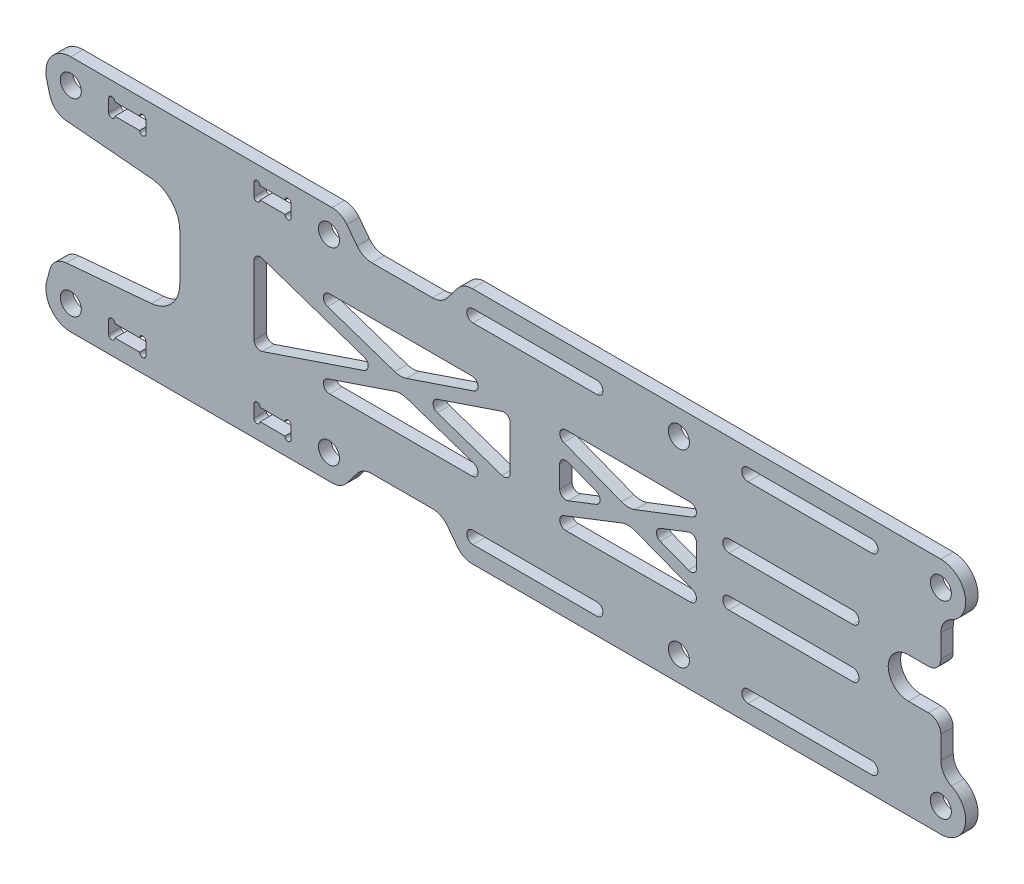
from build123d import *

# Parameters (mm, degrees)
BOSS_EXTRUDE1_DEPTH      = 2
M3_CLEARANCE_HOLE1_D     = 3.4
M3_CLEARANCE_HOLE1_DEPTH = 2


with BuildPart() as part:
    # Sketch1 → Boss-Extrude1 (new body)
    with BuildSketch(Plane.XY):
        with BuildLine():
            Line((-70.9498441, 19.25), (-28.751239803, 19.25))
            ThreePointArc((-28.751239803, 19.25), (-27.425268349, 18.941059216), (-26.372394669, 18.077866469))
            Line((-26.372394669, 18.077866469), (-24.716158925, 15.922387167))
            ThreePointArc((-24.716158925, 15.922387167), (-23.663285245, 15.05919442), (-22.337313791, 14.750253636))
            Line((-22.337313791, 14.750253636), (-12.526963734, 14.750253636))
            ThreePointArc((-12.526963734, 14.750253636), (-11.200992281, 15.05919442), (-10.1481186, 15.922387167))
            Line((-10.1481186, 15.922387167), (-8.491882857, 18.077866469))
            ThreePointArc((-8.491882857, 18.077866469), (-7.439009177, 18.941059216), (-6.113037723, 19.25))
            Line((-6.113037723, 19.25), (69.560347596, 19.25))
            ThreePointArc((69.560347596, 19.25), (73.462662706, 16.128599327), (71.27463331, 11.635968388))
            ThreePointArc((71.27463331, 11.635968388), (70.024884831, 10.529012131), (69.560347596, 8.92544468))
            Line((69.560347596, 8.92544468), (69.560347596, 5.25))
            ThreePointArc((69.560347596, 5.25), (68.974561158, 3.835786438), (67.560347596, 3.25))
            Line((67.560347596, 3.25), (64.309156116, 3.25))
            ThreePointArc((64.309156116, 3.25), (61.059156116, 0), (64.309156116, -3.25))
            Line((64.309156116, -3.25), (67.560347596, -3.25))
            ThreePointArc((67.560347596, -3.25), (68.974561158, -3.835786438), (69.560347596, -5.25))
            Line((69.560347596, -5.25), (69.560347596, -8.92544468))
            ThreePointArc((69.560347596, -8.92544468), (70.024884831, -10.529012131), (71.27463331, -11.635968388))
            ThreePointArc((71.27463331, -11.635968388), (73.462662706, -16.128599327), (69.560347596, -19.25))
            Line((69.560347596, -19.25), (-6.113037723, -19.25))
            ThreePointArc((-6.113037723, -19.25), (-7.439009177, -18.941059216), (-8.491882857, -18.077866469))
            Line((-8.491882857, -18.077866469), (-10.1481186, -15.922387167))
            ThreePointArc((-10.1481186, -15.922387167), (-11.200992281, -15.05919442), (-12.526963734, -14.750253636))
            Line((-12.526963734, -14.750253636), (-22.337313791, -14.750253636))
            ThreePointArc((-22.337313791, -14.750253636), (-23.663285245, -15.05919442), (-24.716158925, -15.922387167))
            Line((-24.716158925, -15.922387167), (-26.372394669, -18.077866469))
            ThreePointArc((-26.372394669, -18.077866469), (-27.425268349, -18.941059216), (-28.751239803, -19.25))
            Line((-28.751239803, -19.25), (-70.9498441, -19.25))
            ThreePointArc((-70.9498441, -19.25), (-73.778271225, -18.078427125), (-74.9498441, -15.25))
            Line((-74.9498441, -15.25), (-74.9498441, -14.5))
            Line((-74.9498441, -14.5), (-74.322497457, -12.158710455))
            ThreePointArc((-74.322497457, -12.158710455), (-73.353082807, -10.637034261), (-71.686187206, -9.946583496))
            Line((-71.686187206, -9.946583496), (-57.912189979, -8.741514887))
            ThreePointArc((-57.912189979, -8.741514887), (-54.661582009, -7.138492435), (-53.347968693, -3.760541396))
            Line((-53.347968693, -3.760541396), (-53.347968693, 3.760541396))
            ThreePointArc((-53.347968693, 3.760541396), (-54.661582009, 7.138492435), (-57.912189979, 8.741514887))
            Line((-57.912189979, 8.741514887), (-71.686187206, 9.946583496))
            ThreePointArc((-71.686187206, 9.946583496), (-73.353082807, 10.637034261), (-74.322497457, 12.158710455))
            Line((-74.322497457, 12.158710455), (-74.9498441, 14.5))
            Line((-74.9498441, 14.5), (-74.9498441, 15.25))
            ThreePointArc((-74.9498441, 15.25), (-73.778271225, 18.078427125), (-70.9498441, 19.25))
        make_face()
        with BuildLine():
            Line((-59.831770127, -16.5), (-63.831770127, -16.5))
            ThreePointArc((-63.831770127, -16.5), (-64.331770127, -17), (-64.831770127, -16.5))
            Line((-64.831770127, -16.5), (-64.831770127, -14.5))
            ThreePointArc((-64.831770127, -14.5), (-64.331770127, -14), (-63.831770127, -14.5))
            Line((-63.831770127, -14.5), (-59.831770127, -14.5))
            ThreePointArc((-59.831770127, -14.5), (-59.331770127, -14), (-58.831770127, -14.5))
            Line((-58.831770127, -14.5), (-58.831770127, -16.5))
            ThreePointArc((-58.831770127, -16.5), (-59.331770127, -17), (-59.831770127, -16.5))
        make_face(mode=Mode.SUBTRACT)
        with BuildLine():
            Line((-59.831770127, 16.5), (-63.831770127, 16.5))
            ThreePointArc((-63.831770127, 16.5), (-64.331770127, 17), (-64.831770127, 16.5))
            Line((-64.831770127, 16.5), (-64.831770127, 14.5))
            ThreePointArc((-64.831770127, 14.5), (-64.331770127, 14), (-63.831770127, 14.5))
            Line((-63.831770127, 14.5), (-59.831770127, 14.5))
            ThreePointArc((-59.831770127, 14.5), (-59.331770127, 14), (-58.831770127, 14.5))
            Line((-58.831770127, 14.5), (-58.831770127, 16.5))
            ThreePointArc((-58.831770127, 16.5), (-59.331770127, 17), (-59.831770127, 16.5))
        make_face(mode=Mode.SUBTRACT)
        with BuildLine():
            Line((-36.368073973, -16.5), (-40.368073973, -16.5))
            ThreePointArc((-40.368073973, -16.5), (-40.868073973, -17), (-41.368073973, -16.5))
            Line((-41.368073973, -16.5), (-41.368073973, -14.5))
            ThreePointArc((-41.368073973, -14.5), (-40.868073973, -14), (-40.368073973, -14.5))
            Line((-40.368073973, -14.5), (-36.368073973, -14.5))
            ThreePointArc((-36.368073973, -14.5), (-35.868073973, -14), (-35.368073973, -14.5))
            Line((-35.368073973, -14.5), (-35.368073973, -16.5))
            ThreePointArc((-35.368073973, -16.5), (-35.868073973, -17), (-36.368073973, -16.5))
        make_face(mode=Mode.SUBTRACT)
        with BuildLine():
            Line((-36.368073973, 16.5), (-40.368073973, 16.5))
            ThreePointArc((-40.368073973, 16.5), (-40.868073973, 17), (-41.368073973, 16.5))
            Line((-41.368073973, 16.5), (-41.368073973, 14.5))
            ThreePointArc((-41.368073973, 14.5), (-40.868073973, 14), (-40.368073973, 14.5))
            Line((-40.368073973, 14.5), (-36.368073973, 14.5))
            ThreePointArc((-36.368073973, 14.5), (-35.868073973, 14), (-35.368073973, 14.5))
            Line((-35.368073973, 14.5), (-35.368073973, 16.5))
            ThreePointArc((-35.368073973, 16.5), (-35.868073973, 17), (-36.368073973, 16.5))
        make_face(mode=Mode.SUBTRACT)
        with BuildLine():
            Line((-41.347968693, 5.565646443), (-41.347968693, -5.565646443))
            ThreePointArc((-41.347968693, -5.565646443), (-40.930761468, -6.378267253), (-40.02726353, -6.512825517))
            Line((-40.02726353, -6.512825517), (-23.589536753, -0.947179074))
            ThreePointArc((-23.589536753, -0.947179074), (-22.910241915, 0), (-23.589536753, 0.947179074))
            Line((-23.589536753, 0.947179074), (-40.02726353, 6.512825517))
            ThreePointArc((-40.02726353, 6.512825517), (-40.930761468, 6.378267253), (-41.347968693, 5.565646443))
        make_face(mode=Mode.SUBTRACT)
        with BuildLine():
            Line((-29.478989951, 5.052820926), (-18.636099835, 1.381529048))
            ThreePointArc((-18.636099835, 1.381529048), (-17.673984346, 1.22306627), (-16.711868857, 1.381529048))
            Line((-16.711868857, 1.381529048), (-5.868978741, 5.052820926))
            ThreePointArc((-5.868978741, 5.052820926), (-5.202977496, 6.162512962), (-6.189683904, 7))
            Line((-6.189683904, 7), (-29.158284788, 7))
            ThreePointArc((-29.158284788, 7), (-30.144991197, 6.162512962), (-29.478989951, 5.052820926))
        make_face(mode=Mode.SUBTRACT)
        with BuildLine():
            Line((-11.75843194, -0.947179074), (-1.320705163, -4.481286782))
            ThreePointArc((-1.320705163, -4.481286782), (-0.417207225, -4.346728519), (0, -3.534107708))
            Line((0, -3.534107708), (0, 3.534107708))
            ThreePointArc((0, 3.534107708), (-0.417207225, 4.346728519), (-1.320705163, 4.481286782))
            Line((-1.320705163, 4.481286782), (-11.75843194, 0.947179074))
            ThreePointArc((-11.75843194, 0.947179074), (-12.437726777, 0), (-11.75843194, -0.947179074))
        make_face(mode=Mode.SUBTRACT)
        with BuildLine():
            Line((8.65032624, 5.115982417), (17.999116989, 1.4793274))
            ThreePointArc((17.999116989, 1.4793274), (19.082164138, 1.275242404), (20.165826044, 1.476037545))
            Line((20.165826044, 1.476037545), (29.446861664, 5.053925437))
            ThreePointArc((29.446861664, 5.053925437), (30.070560416, 6.168437951), (29.090196115, 6.986987959))
            Line((29.090196115, 6.986987959), (9.015897043, 7.047948321))
            ThreePointArc((9.015897043, 7.047948321), (8.030295996, 6.233875897), (8.65032624, 5.115982417))
        make_face(mode=Mode.SUBTRACT)
        with BuildLine():
            Line((8, 1.760974288), (8, -1.760974288))
            ThreePointArc((8, -1.760974288), (8.435435601, -2.586363311), (9.36253408, -2.692944803))
            Line((9.36253408, -2.692944803), (13.889490872, -0.931970515))
            ThreePointArc((13.889490872, -0.931970515), (14.526956792, 0), (13.889490872, 0.931970515))
            Line((13.889490872, 0.931970515), (9.36253408, 2.692944803))
            ThreePointArc((9.36253408, 2.692944803), (8.435435601, 2.586363311), (8, 1.760974288))
        make_face(mode=Mode.SUBTRACT)
        with BuildLine():
            Line((30.131286715, 1.753845524), (30.131286715, -1.753845524))
            ThreePointArc((30.131286715, -1.753845524), (29.708061855, -2.557566414), (28.805901365, -2.66336339))
            Line((28.805901365, -2.66336339), (24.256428807, -0.909517867))
            ThreePointArc((24.256428807, -0.909517867), (23.632291268, 0), (24.256428807, 0.909517867))
            Line((24.256428807, 0.909517867), (28.805901365, 2.66336339))
            ThreePointArc((28.805901365, 2.66336339), (29.708061855, 2.557566414), (30.131286715, 1.753845524))
        make_face(mode=Mode.SUBTRACT)
        with BuildLine():
            Line((-16.711868857, -1.381529048), (-5.868978741, -5.052820926))
            ThreePointArc((-5.868978741, -5.052820926), (-5.202977496, -6.162512962), (-6.189683904, -7))
            Line((-6.189683904, -7), (-29.158284788, -7))
            ThreePointArc((-29.158284788, -7), (-30.144991197, -6.162512962), (-29.478989951, -5.052820926))
            Line((-29.478989951, -5.052820926), (-18.636099835, -1.381529048))
            ThreePointArc((-18.636099835, -1.381529048), (-17.673984346, -1.22306627), (-16.711868857, -1.381529048))
        make_face(mode=Mode.SUBTRACT)
        with BuildLine():
            Line((8.65032624, -5.115982417), (17.999116989, -1.4793274))
            ThreePointArc((17.999116989, -1.4793274), (19.082164138, -1.275242404), (20.165826044, -1.476037545))
            Line((20.165826044, -1.476037545), (29.446861664, -5.053925437))
            ThreePointArc((29.446861664, -5.053925437), (30.070560416, -6.168437951), (29.090196115, -6.986987959))
            Line((29.090196115, -6.986987959), (9.015897043, -7.047948321))
            ThreePointArc((9.015897043, -7.047948321), (8.030295996, -6.233875897), (8.65032624, -5.115982417))
        make_face(mode=Mode.SUBTRACT)
        with BuildLine():
            Line((35.339085007, 5), (55.339085007, 5))
            ThreePointArc((55.339085007, 5), (56.339085007, 4), (55.339085007, 3))
            Line((55.339085007, 3), (35.339085007, 3))
            ThreePointArc((35.339085007, 3), (34.339085007, 4), (35.339085007, 5))
        make_face(mode=Mode.SUBTRACT)
        with BuildLine():
            Line((35.339085007, -5), (55.339085007, -5))
            ThreePointArc((55.339085007, -5), (56.339085007, -4), (55.339085007, -3))
            Line((55.339085007, -3), (35.339085007, -3))
            ThreePointArc((35.339085007, -3), (34.339085007, -4), (35.339085007, -5))
        make_face(mode=Mode.SUBTRACT)
        with BuildLine():
            Line((38.405173798, 16.5), (58.405173798, 16.5))
            ThreePointArc((58.405173798, 16.5), (59.405173798, 15.5), (58.405173798, 14.5))
            Line((58.405173798, 14.5), (38.405173798, 14.5))
            ThreePointArc((38.405173798, 14.5), (37.405173798, 15.5), (38.405173798, 16.5))
        make_face(mode=Mode.SUBTRACT)
        with BuildLine():
            Line((-6.004826202, 16.5), (13.995173798, 16.5))
            ThreePointArc((13.995173798, 16.5), (14.995173798, 15.5), (13.995173798, 14.5))
            Line((13.995173798, 14.5), (-6.004826202, 14.5))
            ThreePointArc((-6.004826202, 14.5), (-7.004826202, 15.5), (-6.004826202, 16.5))
        make_face(mode=Mode.SUBTRACT)
        with BuildLine():
            Line((-6.004826202, -16.5), (13.995173798, -16.5))
            ThreePointArc((13.995173798, -16.5), (14.995173798, -15.5), (13.995173798, -14.5))
            Line((13.995173798, -14.5), (-6.004826202, -14.5))
            ThreePointArc((-6.004826202, -14.5), (-7.004826202, -15.5), (-6.004826202, -16.5))
        make_face(mode=Mode.SUBTRACT)
        with BuildLine():
            Line((38.405173798, -16.5), (58.405173798, -16.5))
            ThreePointArc((58.405173798, -16.5), (59.405173798, -15.5), (58.405173798, -14.5))
            Line((58.405173798, -14.5), (38.405173798, -14.5))
            ThreePointArc((38.405173798, -14.5), (37.405173798, -15.5), (38.405173798, -16.5))
        make_face(mode=Mode.SUBTRACT)
    extrude(amount=BOSS_EXTRUDE1_DEPTH)

    # M3 Clearance Hole1
    with Locations(Plane.XY.offset(2)):
        with Locations((-70.9498441, 15.25), (-70.9498441, -15.25), (-29.25, -15.25), (-29.25, 15.25), (27.25, 15.25), (27.25, -15.25), (69.560347596, -15.25), (69.560347596, 15.25)):
            Hole(M3_CLEARANCE_HOLE1_D / 2, depth=M3_CLEARANCE_HOLE1_DEPTH)


solid = part.part
